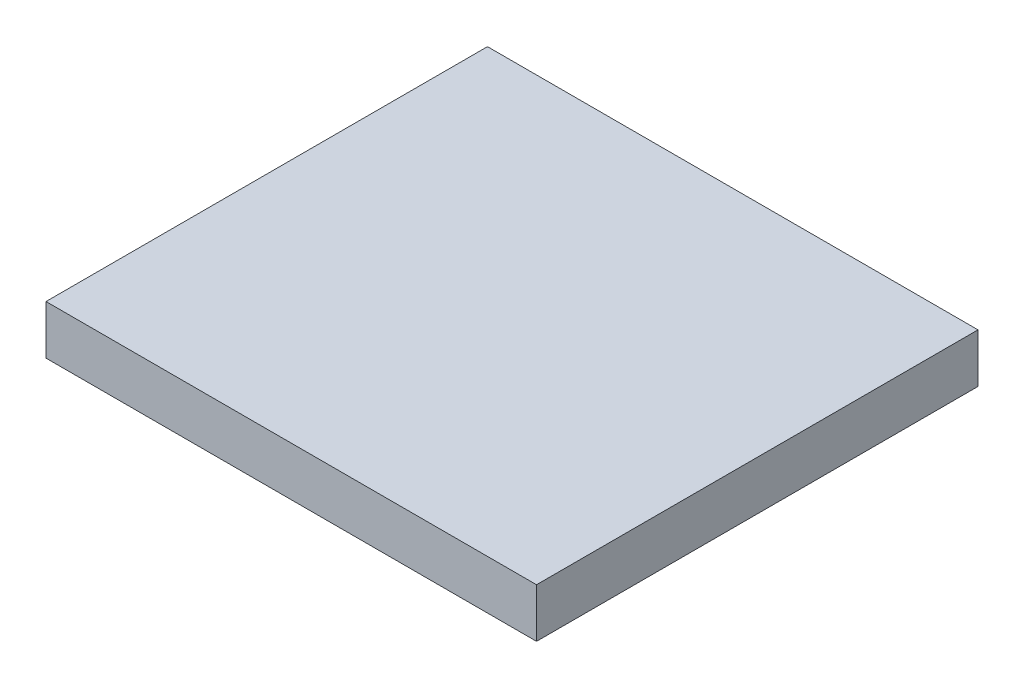
from build123d import *

# Parameters (mm, degrees)
SKETCH1_W           = 100
SKETCH1_H           = 90
BOSS_EXTRUDE1_DEPTH = 10


with BuildPart() as part:
    # Sketch1 → Boss-Extrude1 (new body)
    with BuildSketch(Plane(origin=(0, 0, 0), x_dir=(1, 0, 0), z_dir=(0, 1, 0))):
        with Locations((50, 45)):
            Rectangle(SKETCH1_W, SKETCH1_H)
    extrude(amount=BOSS_EXTRUDE1_DEPTH)


solid = part.part
